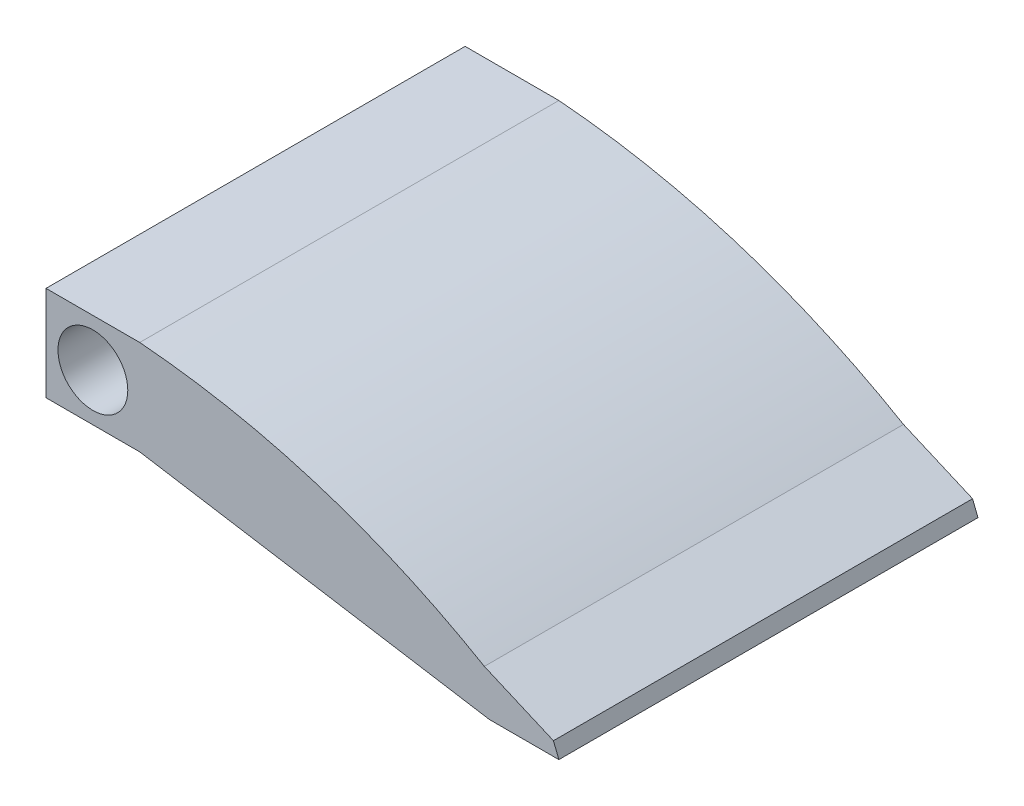
from build123d import *

# Parameters (mm, degrees)
SKETCH1_W           = 6.73955421
SKETCH1_H           = 6.812677774
SKETCH1_R           = 2.51
BOSS_EXTRUDE1_DEPTH = 30.13


with BuildPart() as part:
    # Sketch1 → Boss-Extrude1 (new body)
    with BuildSketch(Plane.XY):
        Rectangle(SKETCH1_W, SKETCH1_H)
        Circle(SKETCH1_R, mode=Mode.SUBTRACT)
        with BuildLine():
            add(Edge.make_bspline(
                [(28.500199806, -7.5), (3.369777105, -3.406338887)],
                knots=[0, 0, 1, 1], degree=1))
            Line((3.369777105, -3.406338887), (3.369777105, 3.406338887))
            add(Edge.make_bspline(
                [(28.143383308, -4.373850119), (16.666117653, 2.316528631), (3.369777105, 3.406338887)],
                knots=[0, 0, 0, 1, 1, 1], degree=2))
            Line((28.143383308, -4.373850119), (33.109649153, -6.51665119))
            Line((33.109649153, -6.51665119), (33.500199806, -7.5))
            Line((33.500199806, -7.5), (28.500199806, -7.5))
        make_face()
    extrude(amount=BOSS_EXTRUDE1_DEPTH)


solid = part.part
